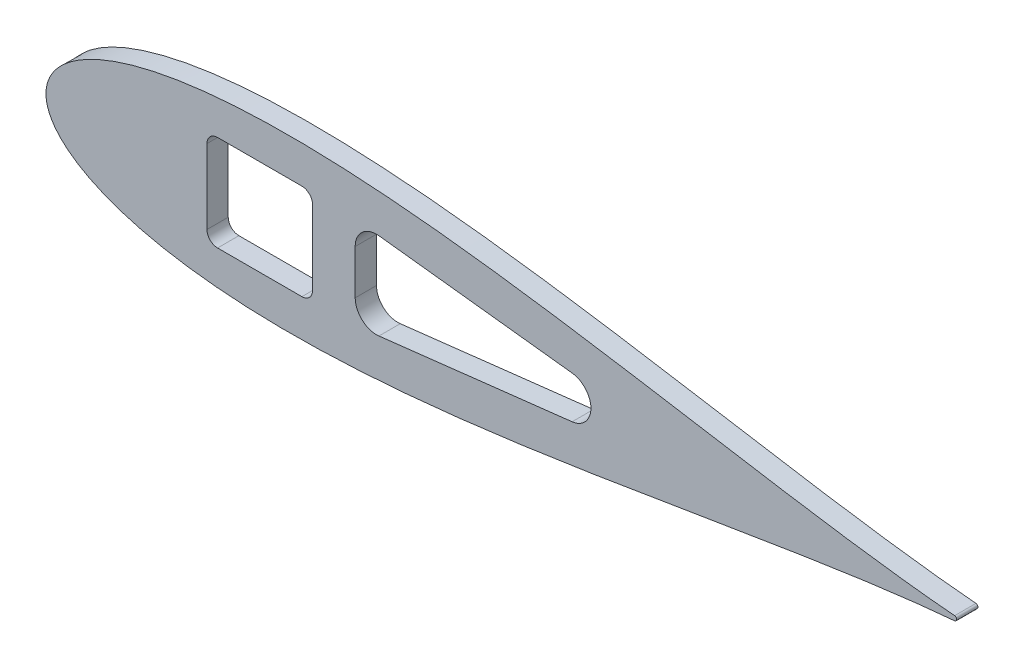
from build123d import *

# Parameters (mm, degrees)
BOSS_EXTRUDE1_DEPTH = 5.4737
SCALE1_SCALE        = 0.337
BOSS_EXTRUDE2_DEPTH = 5.08
SKETCH10_W          = 25.167167629
SKETCH10_H          = 22.8092
CUT_EXTRUDE6_DEPTH  = 6.0800001
FILLET1_R           = 2.54
CUT_EXTRUDE7_DEPTH  = 6.0800001
FILLET2_R           = 5.08
FILLET3_R           = 5.057232


with BuildPart() as part:
    # Sketch2 → Boss-Extrude1 (new body)
    with BuildSketch(Plane.XY):
        with BuildLine():
            add(Edge.make_bspline(
                [(642.510849283, 1.582039112), (641.993392355, 1.625070631), (638.093728429, 1.953546407), (630.413817462, 2.663385493), (619.014124193, 3.849253664), (606.374988512, 5.304428983), (592.543922516, 7.037634907), (577.585454095, 9.050636147), (561.564270734, 11.338919625), (544.549749946, 13.890665375), (526.614143658, 16.687720753), (507.832591566, 19.705111663), (488.282710288, 22.911672601), (468.044367735, 26.27043606), (447.199424328, 29.739007432), (425.831595832, 33.270324121), (404.02631566, 36.813220545), (381.870662856, 40.313266856), (359.453314895, 43.713502532), (336.86454415, 46.955447457), (314.196207315, 49.979843895), (291.541767704, 52.727712704), (268.996310773, 55.141201012), (246.65655865, 57.164603829), (224.620860897, 58.745176641), (202.989192599, 59.8341217), (181.863132616, 60.387506142), (161.345829027, 60.366961324), (141.542033828, 59.739895824), (122.558104573, 58.481758104), (104.502313427, 56.574303932), (87.485018636, 54.008935199), (71.619696083, 50.784752003), (57.023709725, 46.912543066), (43.82045433, 42.41500246), (32.141645239, 37.332204029), (22.129107375, 31.731455339), (13.932423524, 25.726412106), (7.689616489, 19.513207632), (3.463136343, 13.420354421), (1.106333228, 7.923389435), (0.154611582, 3.513796615), (-0.062151598, 0), (0.154611582, -3.513796615), (1.106333228, -7.923389435), (3.463136343, -13.420354421), (7.689616489, -19.513207632), (13.932423524, -25.726412106), (22.129107375, -31.731455339), (32.141645239, -37.332204029), (43.82045433, -42.41500246), (57.023709725, -46.912543066), (71.619696083, -50.784752003), (87.485018636, -54.008935199), (104.502313427, -56.574303932), (122.558104573, -58.481758104), (141.542033828, -59.739895824), (161.345829027, -60.366961324), (181.863132616, -60.387506142), (202.989192599, -59.8341217), (224.620860897, -58.745176641), (246.65655865, -57.164603829), (268.996310773, -55.141201012), (291.541767704, -52.727712704), (314.196207315, -49.979843895), (336.86454415, -46.955447457), (359.453314895, -43.713502532), (381.870662856, -40.313266856), (404.02631566, -36.813220545), (425.831595832, -33.270324121), (447.199424328, -29.739007432), (468.044367735, -26.27043606), (488.282710288, -22.911672601), (507.832591566, -19.705111663), (526.614143658, -16.687720753), (544.549749946, -13.890665375), (561.564270734, -11.338919625), (577.585454095, -9.050636147), (592.543922516, -7.037634907), (606.374988512, -5.304428983), (619.014124193, -3.849253664), (630.413817462, -2.663385493), (638.093728429, -1.953546407), (641.993392355, -1.625070631), (642.510849283, -1.582039112)],
                knots=[0.020157042, 0.020157042, 0.020157042, 0.020157042, 0.021270888, 0.028552555, 0.036780684, 0.045920102, 0.055931764, 0.066772884, 0.07839713, 0.090754827, 0.103793165, 0.117456432, 0.131686226, 0.146421738, 0.161599998, 0.177156133, 0.193023668, 0.209134786, 0.225420633, 0.241811602, 0.258237647, 0.274628557, 0.290914287, 0.307025229, 0.322892517, 0.338448342, 0.353626207, 0.368361232, 0.382590428, 0.396252961, 0.409290412, 0.42164701, 0.433269881, 0.444109249, 0.45411864, 0.463255055, 0.471479114, 0.478755289, 0.485052318, 0.490344026, 0.494609833, 0.497833231, 0.5, 0.502166769, 0.505390167, 0.509655974, 0.514947682, 0.521244711, 0.528520886, 0.536744945, 0.54588136, 0.555890751, 0.566730119, 0.57835299, 0.590709588, 0.603747039, 0.617409572, 0.631638768, 0.646373793, 0.661551658, 0.677107483, 0.692974771, 0.709085713, 0.725371443, 0.741762353, 0.758188398, 0.774579367, 0.790865214, 0.806976332, 0.822843867, 0.838400002, 0.853578262, 0.868313774, 0.882543568, 0.896206835, 0.909245173, 0.92160287, 0.933227116, 0.944068236, 0.954079898, 0.963219316, 0.971447445, 0.978729112, 0.979842958, 0.979842958, 0.979842958, 0.979842958], degree=3))
            ThreePointArc((642.510849283, -1.582039112), (643.966787522, 0), (642.510849283, 1.582039112))
        make_face()
    extrude(amount=BOSS_EXTRUDE1_DEPTH)


with BuildPart() as part_1:
    # Scale1: scaled about (0, 0, 0)
    add(part.part.scale(SCALE1_SCALE))

    # Sketch11 → Boss-Extrude2 (add)
    with BuildSketch(Plane(origin=(0, 0, 0), x_dir=(-1, 0, 0), z_dir=(0, 0, -1))):
        with BuildLine():
            ThreePointArc((-216.526156208, 0.533147181), (-217.016807395, 0), (-216.526156208, -0.533147181))
            add(Edge.make_bspline(
                [(-216.526156208, -0.533147181), (-216.351773223, -0.547648803), (-215.03758648, -0.658345139), (-212.449456485, -0.897560911), (-208.607759853, -1.297198485), (-204.348371129, -1.787592567), (-199.687301888, -2.371682964), (-194.64629803, -3.050064382), (-189.247159238, -3.821215914), (-183.513265732, -4.681154231), (-177.468966413, -5.623761894), (-171.139583358, -6.64062263), (-164.551273367, -7.721233667), (-157.730951927, -8.853136952), (-150.706205999, -10.022045505), (-143.505247795, -11.212099229), (-136.156868377, -12.406055324), (-128.690413382, -13.585570931), (-121.13576712, -14.731450353), (-113.523351379, -15.823985793), (-105.884121865, -16.843207393), (-98.249575716, -17.769239181), (-90.651756731, -18.582584741), (-83.123260265, -19.26447149), (-75.697230122, -19.797124528), (-68.407357906, -20.164099013), (-61.287875692, -20.35058957), (-54.373544382, -20.343665966), (-47.6996654, -20.132344893), (-41.302081241, -19.708352481), (-35.217279625, -19.065540425), (-29.48245128, -18.201011162), (-24.13583758, -17.114461425), (-19.216990177, -15.809527013), (-14.767493109, -14.293855829), (-10.831734446, -12.580952758), (-7.457509185, -10.693500449), (-4.695226728, -8.66980088), (-2.591400757, -6.575950972), (-1.167076948, -4.52265944), (-0.372834298, -2.67018224), (-0.052104103, -1.184149459), (0.020945088, 0), (-0.052104103, 1.184149459), (-0.372834298, 2.67018224), (-1.167076948, 4.52265944), (-2.591400757, 6.575950972), (-4.695226728, 8.66980088), (-7.457509185, 10.693500449), (-10.831734446, 12.580952758), (-14.767493109, 14.293855829), (-19.216990177, 15.809527013), (-24.13583758, 17.114461425), (-29.48245128, 18.201011162), (-35.217279625, 19.065540425), (-41.302081241, 19.708352481), (-47.6996654, 20.132344893), (-54.373544382, 20.343665966), (-61.287875692, 20.35058957), (-68.407357906, 20.164099013), (-75.697230122, 19.797124528), (-83.123260265, 19.26447149), (-90.651756731, 18.582584741), (-98.249575716, 17.769239181), (-105.884121865, 16.843207393), (-113.523351379, 15.823985793), (-121.13576712, 14.731450353), (-128.690413382, 13.585570931), (-136.156868377, 12.406055324), (-143.505247795, 11.212099229), (-150.706205999, 10.022045505), (-157.730951927, 8.853136952), (-164.551273367, 7.721233667), (-171.139583358, 6.64062263), (-177.468966413, 5.623761894), (-183.513265732, 4.681154231), (-189.247159238, 3.821215914), (-194.64629803, 3.050064382), (-199.687301888, 2.371682964), (-204.348371129, 1.787592567), (-208.607759853, 1.297198485), (-212.449456485, 0.897560911), (-215.03758648, 0.658345139), (-216.351773223, 0.547648803), (-216.526156208, 0.533147181)],
                knots=[0.020157042, 0.020157042, 0.020157042, 0.020157042, 0.021270888, 0.028552555, 0.036780684, 0.045920102, 0.055931764, 0.066772884, 0.07839713, 0.090754827, 0.103793165, 0.117456432, 0.131686226, 0.146421738, 0.161599998, 0.177156133, 0.193023668, 0.209134786, 0.225420633, 0.241811602, 0.258237647, 0.274628557, 0.290914287, 0.307025229, 0.322892517, 0.338448342, 0.353626207, 0.368361232, 0.382590428, 0.396252961, 0.409290412, 0.42164701, 0.433269881, 0.444109249, 0.45411864, 0.463255055, 0.471479114, 0.478755289, 0.485052318, 0.490344026, 0.494609833, 0.497833231, 0.5, 0.502166769, 0.505390167, 0.509655974, 0.514947682, 0.521244711, 0.528520886, 0.536744945, 0.54588136, 0.555890751, 0.566730119, 0.57835299, 0.590709588, 0.603747039, 0.617409572, 0.631638768, 0.646373793, 0.661551658, 0.677107483, 0.692974771, 0.709085713, 0.725371443, 0.741762353, 0.758188398, 0.774579367, 0.790865214, 0.806976332, 0.822843867, 0.838400002, 0.853578262, 0.868313774, 0.882543568, 0.896206835, 0.909245173, 0.92160287, 0.933227116, 0.944068236, 0.954079898, 0.963219316, 0.971447445, 0.978729112, 0.979842958, 0.979842958, 0.979842958, 0.979842958], degree=3))
        make_face()
    extrude(amount=-BOSS_EXTRUDE2_DEPTH)

    # Sketch10 → Cut-Extrude6 (cut, through all)
    with BuildSketch(Plane.XY):
        with Locations((50.937583815, 0)):
            Rectangle(SKETCH10_W, SKETCH10_H)
    extrude(amount=CUT_EXTRUDE6_DEPTH, mode=Mode.SUBTRACT)

    # Fillet1
    fillet1_edges = [part_1.edges().sort_by_distance(p)[0] for p in [
        (63.521167629, -11.4046, 2.54),
        (63.521167629, 11.4046, 2.54),
        (38.354, 11.4046, 2.54),
        (38.354, -11.4046, 2.54),
    ]]
    fillet(fillet1_edges, radius=FILLET1_R)

    # Sketch12 → Cut-Extrude7 (cut, through all)
    with BuildSketch(Plane(origin=(0, 0, 0), x_dir=(-1, 0, 0), z_dir=(0, 0, -1))):
        Polygon((-73.681167629, -10.997997422), (-73.681167629, 10.997997422), (-129.8570984, 4.506488496), (-129.8570984, -4.506488496), align=None)
    extrude(amount=-CUT_EXTRUDE7_DEPTH, mode=Mode.SUBTRACT)

    # Fillet2
    fillet2_edges = [part_1.edges().sort_by_distance(p)[0] for p in [
        (73.681167629, -10.997997422, 2.54),
        (73.681167629, 10.997997422, 2.54),
    ]]
    fillet(fillet2_edges, radius=FILLET2_R)

    # Fillet3
    fillet3_edges = [part_1.edges().sort_by_distance(p)[0] for p in [
        (129.8570984, -4.506488496, 2.54),
        (129.8570984, 4.506488496, 2.54),
    ]]
    fillet(fillet3_edges, radius=FILLET3_R)


solid = part_1.part
